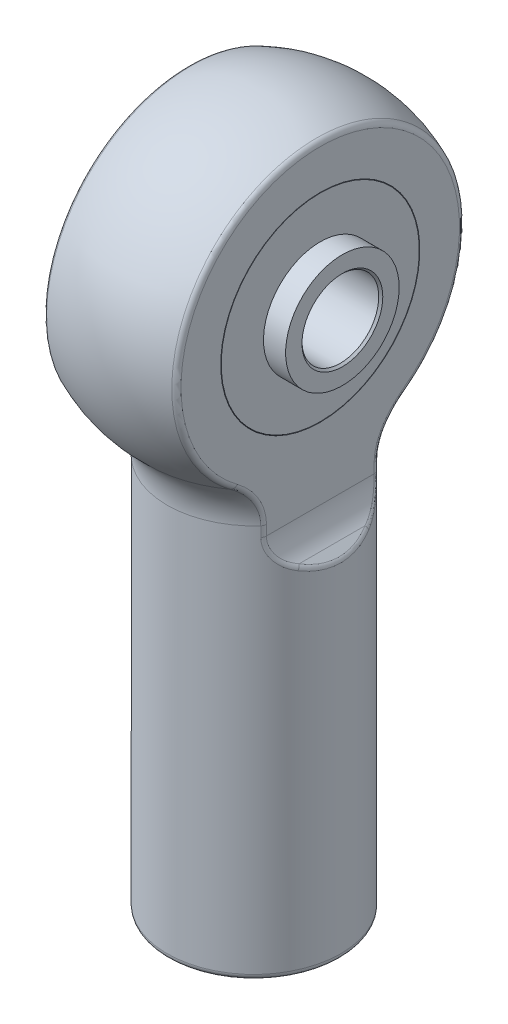
from build123d import *

# Parameters (mm, degrees)
EXTRUDE1_DEPTH      = 10.9187
EXTRUDE1_DEPTH_BACK = 10.9187
SKETCH3_R           = 3.5687
EXTRUDE2_DEPTH      = 1.39065
EXTRUDE2_DEPTH_BACK = 9.72185
FILLET2_R           = 3.81
FILLET1_R           = 0.381


with BuildPart() as part:
    # Sketch1 → Revolve1 (revolve)
    with BuildSketch(Plane.XY):
        with BuildLine():
            Line((-3.4544, -34.925), (-5.461, -34.925))
            Line((-5.461, -34.925), (-5.461, -8.279981201))
            ThreePointArc((-5.461, -8.279981201), (-9.50019103, 2.85078587), (0, 9.9187))
            Line((0, 9.9187), (0, -10.863262939))
            Line((0, -10.863262939), (-3.4544, -12.7))
            Line((-3.4544, -12.7), (-3.4544, -34.925))
        make_face()
    revolve(axis=Axis((0, 0, 0), (0, -1, 0)))

    # Sketch2 → Extrude1 (cut, two sides)
    with BuildSketch(Plane.XY) as extrude1_sk:
        with BuildLine():
            Line((4.1656, 9.00157688), (4.1656, -10.758478753))
            ThreePointArc((4.1656, -10.758478753), (4.358945987, -11.730494671), (4.909548776, -12.554529977))
            Line((4.909548776, -12.554529977), (5.461, -13.105981201))
            Line((5.461, -13.105981201), (5.461, -8.279981201))
            ThreePointArc((5.461, -8.279981201), (9.890951386, 0.741411068), (4.1656, 9.00157688))
        make_face()
        with BuildLine():
            Line((-4.1656, 9.00157688), (-4.1656, -10.758478753))
            ThreePointArc((-4.1656, -10.758478753), (-4.358945987, -11.730494671), (-4.909548776, -12.554529977))
            Line((-4.909548776, -12.554529977), (-5.461, -13.105981201))
            Line((-5.461, -13.105981201), (-5.461, -8.279981201))
            ThreePointArc((-5.461, -8.279981201), (-9.890951386, 0.741411068), (-4.1656, 9.00157688))
        make_face()
    extrude(amount=EXTRUDE1_DEPTH, mode=Mode.SUBTRACT)
    extrude(extrude1_sk.sketch, amount=-EXTRUDE1_DEPTH_BACK, mode=Mode.SUBTRACT)

    # Sketch3 → Extrude2 (add, two sides)
    with BuildSketch(Plane(origin=(4.1656, 0, 0), x_dir=(0, 0, -1), z_dir=(1, 0, 0))) as extrude2_sk:
        Circle(SKETCH3_R)
    extrude(amount=EXTRUDE2_DEPTH)
    extrude(extrude2_sk.sketch, amount=-EXTRUDE2_DEPTH_BACK)

    # Sketch4 → #11 (0.191) Diameter Hole1 (revolve, cut)
    with BuildSketch(Plane(origin=(5.55625, 0, 0), x_dir=(0, 0, -1), z_dir=(0, 1, 0))):
        Polygon((0, 0), (0, 11.1125), (2.54, 11.1125), (2.413, 10.9855), (2.413, 0.127), (2.54, 0), align=None)
    revolve(axis=Axis((11.90625, 0, 0), (-1, 0, 0)), mode=Mode.SUBTRACT)

    # Fillet2
    fillet2_edges = [part.edges().sort_by_distance(p)[0] for p in [
        (0, -8.279981201, -5.461),
        (0, -8.279981201, 5.461),
    ]]
    fillet(fillet2_edges, radius=FILLET2_R)

    # Fillet1
    fillet1_edges = [part.edges().sort_by_distance(p)[0] for p in [
        (4.416213046, -11.858618455, -3.212410832),
        (5.314891458, -12.959872659, -1.254770811),
        (4.416213046, -11.858618455, 3.212410832),
        (4.1656, -10.441989683, -3.53133086),
        (-5.314891458, -12.959872659, -1.254770811),
        (-4.416213046, -11.858618455, -3.212410832),
        (-4.416213046, -11.858618455, 3.212410832),
        (-4.1656, -10.441989683, 3.53133086),
        (5.461, -34.925, 0),
        (-4.1656, 2.754790248, -8.569685935),
        (4.1656, 2.754790248, -8.569685935),
        (-4.1656, -10.441989683, -3.53133086),
        (4.1656, -10.441989683, 3.53133086),
        (4.1656, -8.526134484, 4.054402063),
        (-4.1656, -8.526134484, 4.054402063),
        (-4.1656, -8.526134484, -4.054402063),
        (4.1656, -8.526134484, -4.054402063),
    ]]
    fillet(fillet1_edges, radius=FILLET1_R)

    # Sketch6 → Cut-Revolve1 (revolve, cut)
    with BuildSketch(Plane(origin=(0, 0, 0), x_dir=(0, 0, -1), z_dir=(1, 0, 0))):
        with BuildLine():
            Line((-7.5184, 0), (-7.493, 0))
            ThreePointArc((-7.493, 0), (0, 7.493), (7.493, 0))
            Line((7.493, 0), (7.5184, 0))
            ThreePointArc((7.5184, 0), (0, 7.5184), (-7.5184, 0))
        make_face()
    revolve(axis=Axis((0, 0, -7.493), (0, 0, -1)), mode=Mode.SUBTRACT)


solid = part.part
